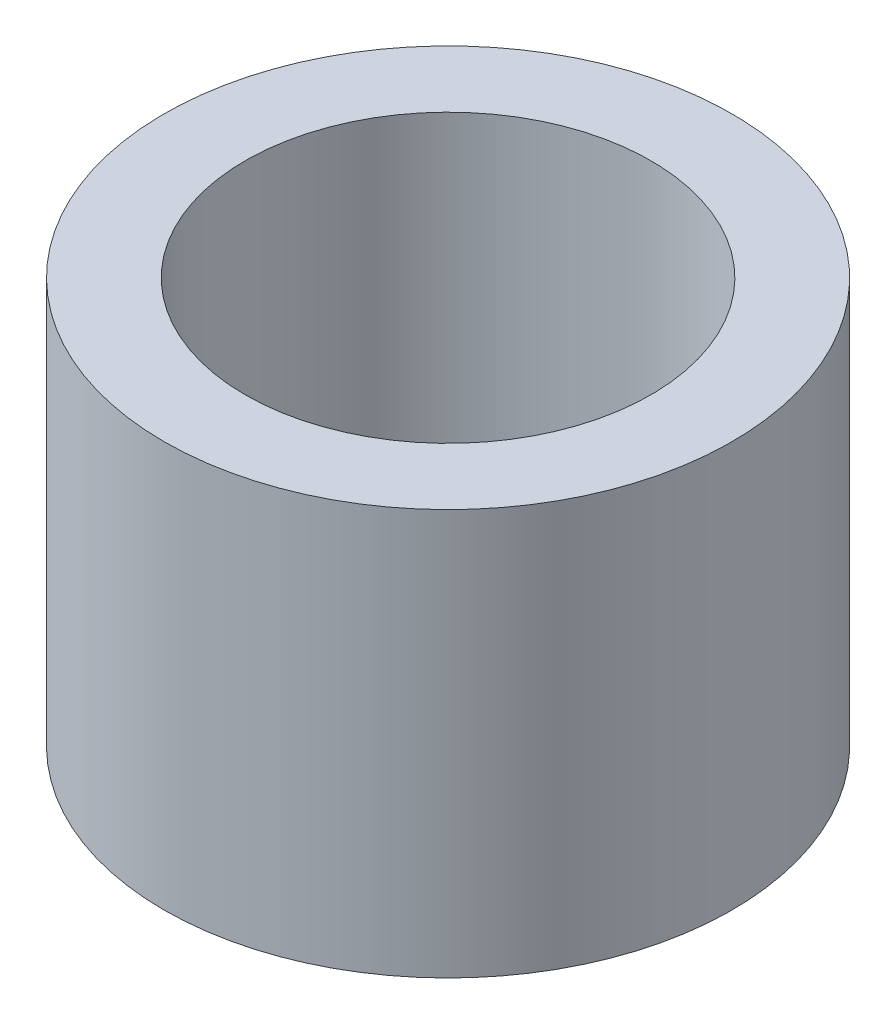
from build123d import *

# Parameters (mm, degrees)
SKETCH1_R           = 3.5
SKETCH1_R_2         = 2.5
BOSS_EXTRUDE1_DEPTH = 5


with BuildPart() as part:
    # Sketch1 → Boss-Extrude1 (new body)
    with BuildSketch(Plane(origin=(0, 0, 0), x_dir=(1, 0, 0), z_dir=(0, 1, 0))):
        Circle(SKETCH1_R)
        Circle(SKETCH1_R_2, mode=Mode.SUBTRACT)
    extrude(amount=BOSS_EXTRUDE1_DEPTH)


solid = part.part
